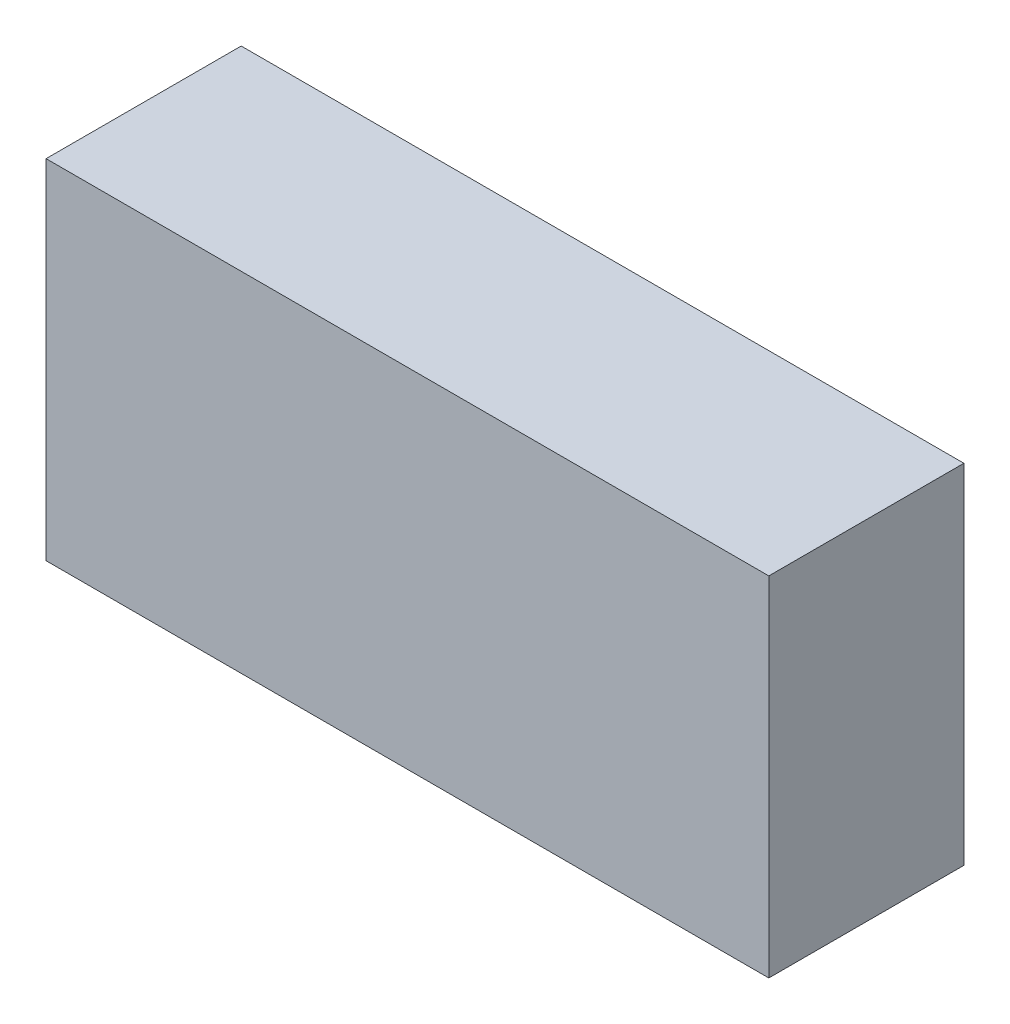
from build123d import *

# Parameters (mm, degrees)
SKETCH1_W           = 202
SKETCH1_H           = 97.33
BOSS_EXTRUDE1_DEPTH = 54.53


with BuildPart() as part:
    # Sketch1 → Boss-Extrude1 (new body)
    with BuildSketch(Plane.XY):
        with Locations((101, 48.665)):
            Rectangle(SKETCH1_W, SKETCH1_H)
    extrude(amount=BOSS_EXTRUDE1_DEPTH)


solid = part.part
